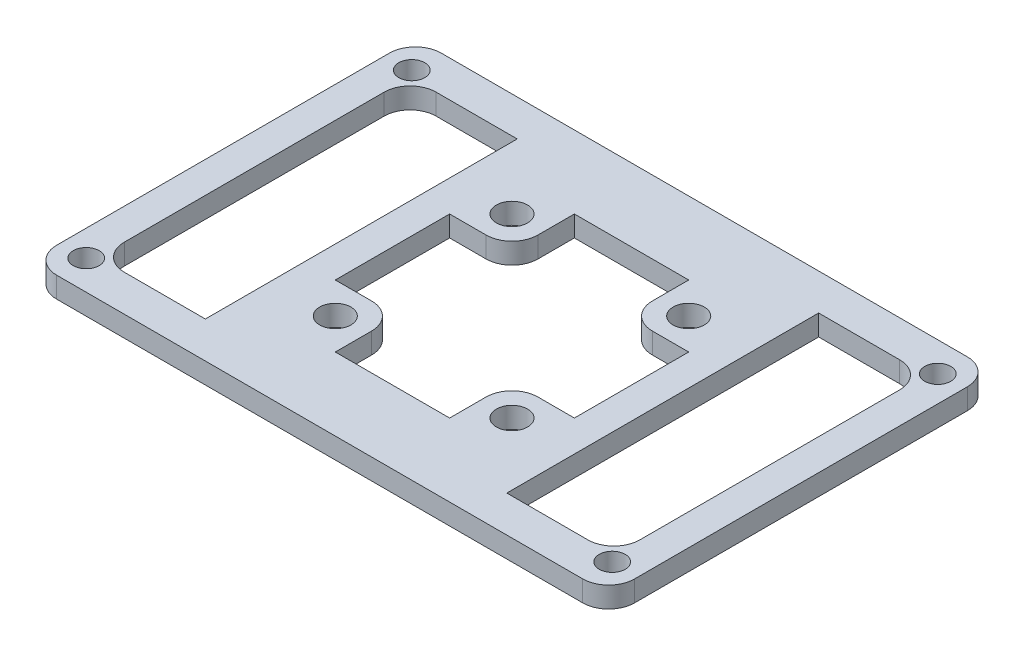
from build123d import *

# Parameters (mm, degrees)
SKETCH1_W           = 55.6
SKETCH1_H           = 37
BOSS_EXTRUDE1_DEPTH = 2
CUT_EXTRUDE2_REACH  = 4
FILLET2_R           = 2.5
CUT_EXTRUDE3_REACH  = 4
CUT_EXTRUDE4_REACH  = 4
SKETCH7_R           = 1.25
CUT_EXTRUDE5_DEPTH  = 10


with BuildPart() as part:
    # Sketch1 → Boss-Extrude1 (new body)
    with BuildSketch(Plane(origin=(0, 0, 0), x_dir=(1, 0, 0), z_dir=(0, 1, 0))):
        Rectangle(SKETCH1_W, SKETCH1_H)
    extrude(amount=BOSS_EXTRUDE1_DEPTH)

    # Sketch5 → Cut-Extrude2 (cut, up to next)
    with BuildSketch(Plane(origin=(0, 2, 0), x_dir=(1, 0, 0), z_dir=(0, 1, 0)), mode=Mode.PRIVATE) as cut_extrude2_sk1:
        with BuildLine():
            Line((5.5, 11.5), (-5.5, 11.5))
            Line((-5.5, 11.5), (-5.5, 8))
            ThreePointArc((-5.5, 8), (-6.232233047, 6.232233047), (-8, 5.5))
            Line((-8, 5.5), (-11.5, 5.5))
            Line((-11.5, 5.5), (-11.5, -5.5))
            Line((-11.5, -5.5), (-8, -5.5))
            ThreePointArc((-8, -5.5), (-6.232233047, -6.232233047), (-5.5, -8))
            Line((-5.5, -8), (-5.5, -11.5))
            Line((-5.5, -11.5), (5.5, -11.5))
            Line((5.5, -11.5), (5.5, -8))
            ThreePointArc((5.5, -8), (6.232233047, -6.232233047), (8, -5.5))
            Line((8, -5.5), (11.5, -5.5))
            Line((11.5, -5.5), (11.5, 5.5))
            Line((11.5, 5.5), (8, 5.5))
            ThreePointArc((8, 5.5), (6.232233047, 6.232233047), (5.5, 8))
            Line((5.5, 8), (5.5, 11.5))
        make_face()
    cut_extrude2_tool1 = extrude(cut_extrude2_sk1.sketch, amount=-CUT_EXTRUDE2_REACH, mode=Mode.PRIVATE) & part.part
    add(cut_extrude2_tool1.solids().sort_by_distance((0, 2, 0))[0], mode=Mode.SUBTRACT)

    # Fillet2
    fillet2_edges = [part.edges().sort_by_distance(p)[0] for p in [
        (27.8, 1, 18.5),
        (-27.8, 1, 18.5),
        (-27.8, 1, -18.5),
        (27.8, 1, -18.5),
    ]]
    fillet(fillet2_edges, radius=FILLET2_R)

    # Sketch6 → Cut-Extrude3 (cut, up to next)
    with BuildSketch(Plane(origin=(0, 2, 0), x_dir=(1, 0, 0), z_dir=(0, 1, 0)), mode=Mode.PRIVATE) as cut_extrude3_sk1:
        with BuildLine():
            Line((-22.3, 15), (-14.5, 15))
            Line((-14.5, 15), (-14.5, -15))
            Line((-14.5, -15), (-22.3, -15))
            ThreePointArc((-22.3, -15), (-24.067766953, -14.267766953), (-24.8, -12.5))
            Line((-24.8, -12.5), (-24.8, 12.5))
            ThreePointArc((-24.8, 12.5), (-24.067766953, 14.267766953), (-22.3, 15))
        make_face()
    cut_extrude3_tool1 = extrude(cut_extrude3_sk1.sketch, amount=-CUT_EXTRUDE3_REACH, mode=Mode.PRIVATE) & part.part
    add(cut_extrude3_tool1.solids().sort_by_distance((-19.60979, 2, 0))[0], mode=Mode.SUBTRACT)
    # Sketch6 → Cut-Extrude3 (cut, up to next)
    with BuildSketch(Plane(origin=(0, 2, 0), x_dir=(1, 0, 0), z_dir=(0, 1, 0)), mode=Mode.PRIVATE) as cut_extrude3_sk2:
        with BuildLine():
            Line((22.3, -15), (14.5, -15))
            Line((14.5, -15), (14.5, 15))
            Line((14.5, 15), (22.3, 15))
            ThreePointArc((22.3, 15), (24.067766953, 14.267766953), (24.8, 12.5))
            Line((24.8, 12.5), (24.8, -12.5))
            ThreePointArc((24.8, -12.5), (24.067766953, -14.267766953), (22.3, -15))
        make_face()
    cut_extrude3_tool2 = extrude(cut_extrude3_sk2.sketch, amount=-CUT_EXTRUDE3_REACH, mode=Mode.PRIVATE) & part.part
    add(cut_extrude3_tool2.solids().sort_by_distance((19.60979, 2, 0))[0], mode=Mode.SUBTRACT)

    # Sketch7 → Cut-Extrude4 (cut, up to next)
    with BuildSketch(Plane(origin=(0, 2, 0), x_dir=(1, 0, 0), z_dir=(0, 1, 0)), mode=Mode.PRIVATE) as cut_extrude4_sk1:
        with Locations((-25.3, 15.66)):
            Circle(SKETCH7_R)
    cut_extrude4_tool1 = extrude(cut_extrude4_sk1.sketch, amount=-CUT_EXTRUDE4_REACH, mode=Mode.PRIVATE) & part.part
    add(cut_extrude4_tool1.solids().sort_by_distance((-25.3, 2, -15.66))[0], mode=Mode.SUBTRACT)
    # Sketch7 → Cut-Extrude4 (cut, up to next)
    with BuildSketch(Plane(origin=(0, 2, 0), x_dir=(1, 0, 0), z_dir=(0, 1, 0)), mode=Mode.PRIVATE) as cut_extrude4_sk2:
        with Locations((25.3, 15.66)):
            Circle(SKETCH7_R)
    cut_extrude4_tool2 = extrude(cut_extrude4_sk2.sketch, amount=-CUT_EXTRUDE4_REACH, mode=Mode.PRIVATE) & part.part
    add(cut_extrude4_tool2.solids().sort_by_distance((25.3, 2, -15.66))[0], mode=Mode.SUBTRACT)
    # Sketch7 → Cut-Extrude4 (cut, up to next)
    with BuildSketch(Plane(origin=(0, 2, 0), x_dir=(1, 0, 0), z_dir=(0, 1, 0)), mode=Mode.PRIVATE) as cut_extrude4_sk3:
        with Locations((25.3, -15.66)):
            Circle(SKETCH7_R)
    cut_extrude4_tool3 = extrude(cut_extrude4_sk3.sketch, amount=-CUT_EXTRUDE4_REACH, mode=Mode.PRIVATE) & part.part
    add(cut_extrude4_tool3.solids().sort_by_distance((25.3, 2, 15.66))[0], mode=Mode.SUBTRACT)
    # Sketch7 → Cut-Extrude4 (cut, up to next)
    with BuildSketch(Plane(origin=(0, 2, 0), x_dir=(1, 0, 0), z_dir=(0, 1, 0)), mode=Mode.PRIVATE) as cut_extrude4_sk4:
        with Locations((-25.3, -15.66)):
            Circle(SKETCH7_R)
    cut_extrude4_tool4 = extrude(cut_extrude4_sk4.sketch, amount=-CUT_EXTRUDE4_REACH, mode=Mode.PRIVATE) & part.part
    add(cut_extrude4_tool4.solids().sort_by_distance((-25.3, 2, 15.66))[0], mode=Mode.SUBTRACT)

    # Sketch3 → Cut-Extrude5 (cut)
    with BuildSketch(Plane(origin=(0, 2, 0), x_dir=(1, 0, 0), z_dir=(0, 1, 0))):
        with BuildLine():
            Line((-8.5, 7), (-8.5, 8.5))
            Line((-8.5, 8.5), (-7, 8.5))
            ThreePointArc((-7, 8.5), (-9.560660172, 9.560660172), (-8.5, 7))
        make_face()
        with BuildLine():
            Line((-7, 8.5), (-8.5, 8.5))
            Line((-8.5, 8.5), (-8.5, 7))
            ThreePointArc((-8.5, 7), (-7.439339828, 7.439339828), (-7, 8.5))
        make_face()
        with BuildLine():
            ThreePointArc((10, 8.5), (8.5, 10), (7, 8.5))
            Line((7, 8.5), (8.5, 8.5))
            Line((8.5, 8.5), (8.5, 7))
            ThreePointArc((8.5, 7), (9.560660172, 7.439339828), (10, 8.5))
        make_face()
        with BuildLine():
            Line((8.5, 8.5), (7, 8.5))
            ThreePointArc((7, 8.5), (7.439339828, 7.439339828), (8.5, 7))
            Line((8.5, 7), (8.5, 8.5))
        make_face()
        with BuildLine():
            ThreePointArc((-7, -8.5), (-7.439339828, -7.439339828), (-8.5, -7))
            Line((-8.5, -7), (-8.5, -8.5))
            Line((-8.5, -8.5), (-7, -8.5))
        make_face()
        with BuildLine():
            Line((-8.5, -8.5), (-8.5, -7))
            ThreePointArc((-8.5, -7), (-9.560660172, -9.560660172), (-7, -8.5))
            Line((-7, -8.5), (-8.5, -8.5))
        make_face()
        with BuildLine():
            ThreePointArc((10, -8.5), (9.560660172, -7.439339828), (8.5, -7))
            Line((8.5, -7), (8.5, -8.5))
            Line((8.5, -8.5), (7, -8.5))
            ThreePointArc((7, -8.5), (8.5, -10), (10, -8.5))
        make_face()
        with BuildLine():
            Line((8.5, -8.5), (8.5, -7))
            ThreePointArc((8.5, -7), (7.439339828, -7.439339828), (7, -8.5))
            Line((7, -8.5), (8.5, -8.5))
        make_face()
    extrude(amount=-CUT_EXTRUDE5_DEPTH, mode=Mode.SUBTRACT)


solid = part.part
